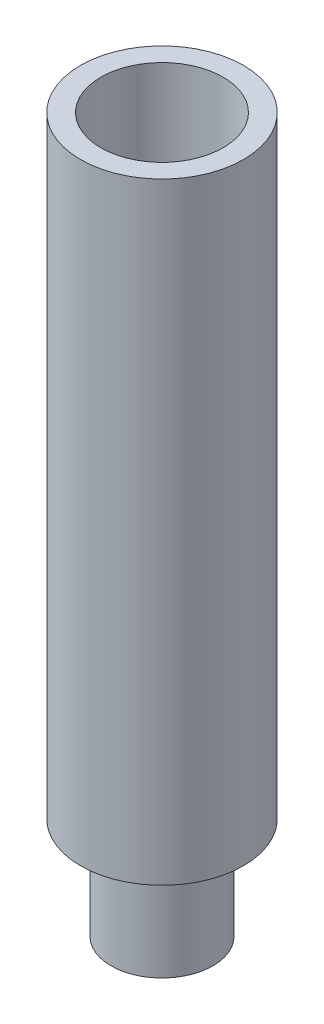
from build123d import *

# Parameters (mm, degrees)
SKETCH1_R           = 2.5
BOSS_EXTRUDE1_DEPTH = 5
BOSS_EXTRUDE2_START = 5
SKETCH1_3_R         = 4
BOSS_EXTRUDE2_DEPTH = 1
BOSS_EXTRUDE3_START = 6
SKETCH1_4_R         = 4
SKETCH1_4_R_2       = 3
BOSS_EXTRUDE3_DEPTH = 29


with BuildPart() as part:
    # Sketch1 → Boss-Extrude1 (new body)
    with BuildSketch(Plane(origin=(0, 0, 0), x_dir=(1, 0, 0), z_dir=(0, 1, 0))):
        Circle(SKETCH1_R)
    extrude(amount=BOSS_EXTRUDE1_DEPTH)

    # Sketch1_3 → Boss-Extrude2 (add)
    with BuildSketch(Plane(origin=(0, 0, 0), x_dir=(1, 0, 0), z_dir=(0, 1, 0)).offset(BOSS_EXTRUDE2_START)):
        Circle(SKETCH1_3_R)
    extrude(amount=BOSS_EXTRUDE2_DEPTH)

    # Sketch1_4 → Boss-Extrude3 (add)
    with BuildSketch(Plane(origin=(0, 0, 0), x_dir=(1, 0, 0), z_dir=(0, 1, 0)).offset(BOSS_EXTRUDE3_START)):
        Circle(SKETCH1_4_R)
        Circle(SKETCH1_4_R_2, mode=Mode.SUBTRACT)
    extrude(amount=BOSS_EXTRUDE3_DEPTH)


solid = part.part
